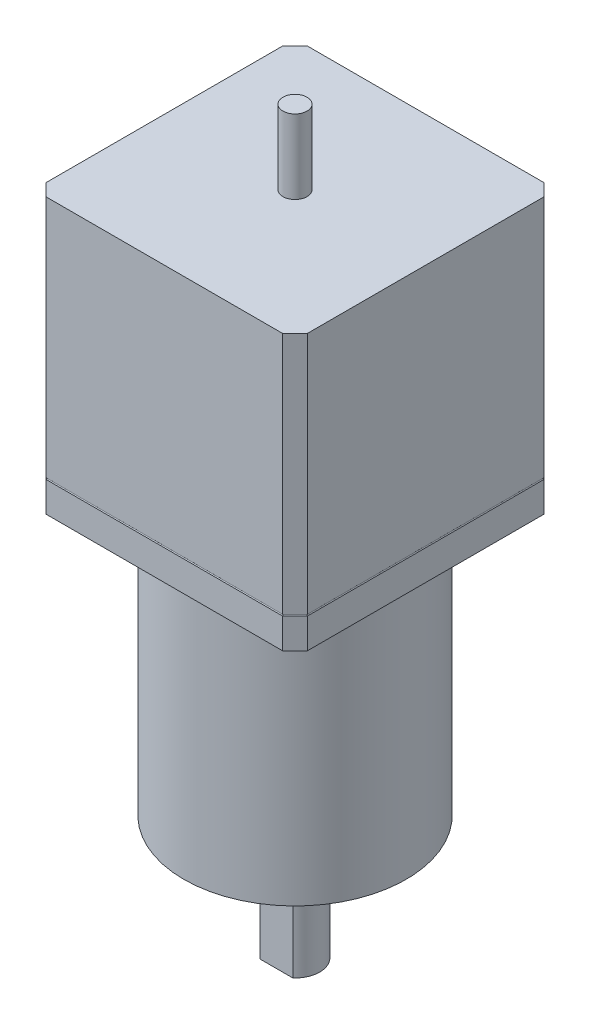
from build123d import *

# Parameters (mm, degrees)
SKETCH1_W           = 42.3
SKETCH1_H           = 42.3
BOSS_EXTRUDE1_DEPTH = 44.5
CHAMFER1_SIZE       = 2
SKETCH3_R           = 1.95
BOSS_EXTRUDE2_DEPTH = 12
SKETCH4_R           = 18
BOSS_EXTRUDE3_DEPTH = 43.2
SKETCH6_R           = 0.125
SKETCH7_R           = 11
BOSS_EXTRUDE4_DEPTH = 2
SKETCH9_R           = 4
BOSS_EXTRUDE5_DEPTH = 18
SKETCH10_W          = 5.291502622
SKETCH10_H          = 3
CUT_EXTRUDE1_DEPTH  = 15
CIRPATTERN1_COUNT   = 4


with BuildPart() as part:
    # Sketch1 → Boss-Extrude1 (new body)
    with BuildSketch(Plane(origin=(0, 0, 0), x_dir=(1, 0, 0), z_dir=(0, 1, 0))):
        with Locations((-21.15, -21.15)):
            Rectangle(SKETCH1_W, SKETCH1_H)
    extrude(amount=BOSS_EXTRUDE1_DEPTH)

    # Chamfer1
    chamfer1_edges = [part.edges().sort_by_distance(p)[0] for p in [
        (0, 22.25, 42.3),
        (-42.3, 22.25, 42.3),
        (-42.3, 22.25, 0),
        (0, 22.25, 0),
    ]]
    chamfer(chamfer1_edges, length=CHAMFER1_SIZE)

    # Sketch3 → Boss-Extrude2 (add)
    with BuildSketch(Plane(origin=(0, 44.5, 0), x_dir=(1, 0, 0), z_dir=(0, 1, 0))):
        with Locations((-21.15, -21.15)):
            Circle(SKETCH3_R)
    extrude(amount=BOSS_EXTRUDE2_DEPTH)

    # Sketch4 → Boss-Extrude3 (add)
    with BuildSketch(Plane.XZ):
        with Locations((-21.15, 21.15)):
            Circle(SKETCH4_R)
    extrude(amount=BOSS_EXTRUDE3_DEPTH)

    # Cut-Sweep2: sweep along a path in Sketch5
    with BuildLine(Plane(origin=(0, 5, 0), x_dir=(-1, 0, 0), z_dir=(0, -1, 0))) as cut_sweep2_path:
        Line((2, 0), (0, -2))
        Line((0, -2), (0, -40.3))
        Line((0, -40.3), (2, -42.3))
        Line((2, -42.3), (40.3, -42.3))
        Line((40.3, -42.3), (42.3, -40.3))
        Line((42.3, -40.3), (42.3, -2))
        Line((42.3, -2), (40.3, 0))
        Line((40.3, 0), (2, 0))
    # Sketch6 → Cut-Sweep2 (sweep, cut)
    with BuildSketch(Plane(origin=(0, 0, 0), x_dir=(0, 0, -1), z_dir=(1, 0, 0))):
        with Locations((-40.3, 5)):
            Circle(SKETCH6_R)
    sweep(path=cut_sweep2_path.line, transition=Transition.RIGHT, mode=Mode.SUBTRACT)

    # Sketch7 → Boss-Extrude4 (add)
    with BuildSketch(Plane.XZ.offset(43.2)):
        with Locations((-21.15, 21.15)):
            Circle(SKETCH7_R)
    extrude(amount=BOSS_EXTRUDE4_DEPTH)

    # Sketch9 → Boss-Extrude5 (add)
    with BuildSketch(Plane.XZ.offset(45.2)):
        with Locations((-21.15, 21.15)):
            Circle(SKETCH9_R)
    extrude(amount=BOSS_EXTRUDE5_DEPTH)

    # Sketch10 → Cut-Extrude1 (cut)
    with BuildSketch(Plane.XZ.offset(63.2)):
        with Locations((-21.15, 25.65)):
            Rectangle(SKETCH10_W, SKETCH10_H)
    extrude(amount=-CUT_EXTRUDE1_DEPTH, mode=Mode.SUBTRACT)

    # Sketch13 → M3 Clearance Hole1 (revolve, cut)
    with BuildSketch(Plane(origin=(-11.250505063, -43.2, 31.049494937), x_dir=(0, 0, -1), z_dir=(1, 0, 0))):
        Polygon((0, 0), (0, 21.021463052), (1.7, 20), (1.7, 0.025), (1.725, 0), align=None)
    m3_clearance_hole1 = revolve(axis=Axis((-11.250505063, -49.55, 31.049494937), (0, 1, 0)), mode=Mode.SUBTRACT)

    # CirPattern1: M3 Clearance Hole1 ×4 about axis
    cirpattern1_axis = Axis((-21.15, 0, 21.15), (0, 1, 0))
    for i in range(1, CIRPATTERN1_COUNT):
        add(m3_clearance_hole1.rotate(cirpattern1_axis, i * 360 / CIRPATTERN1_COUNT), mode=Mode.SUBTRACT)


solid = part.part
